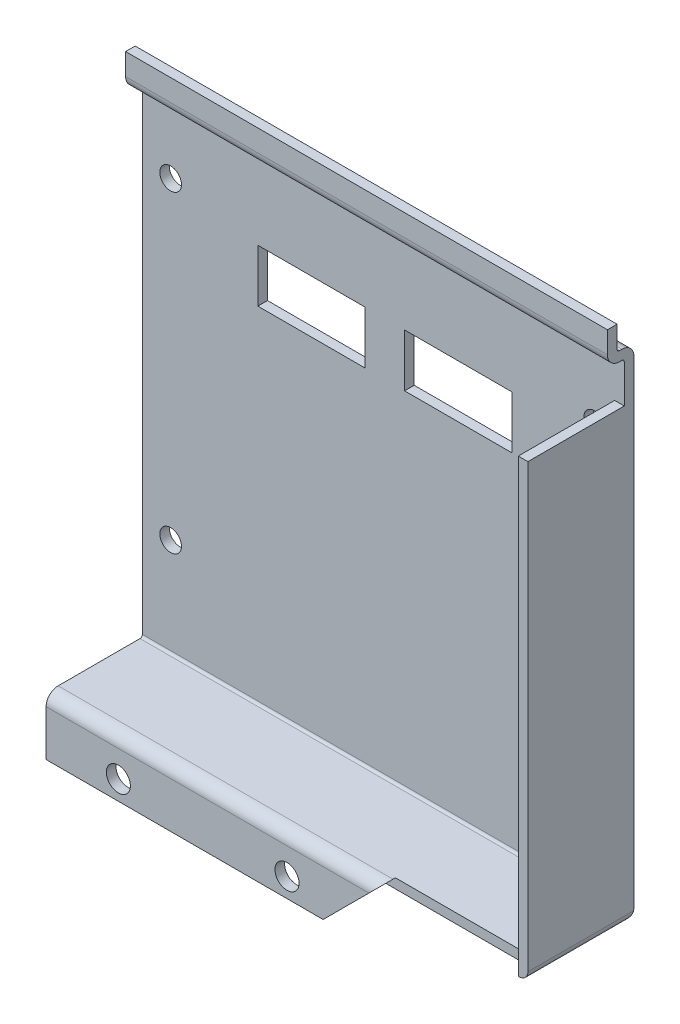
from build123d import *

# Parameters (mm, degrees)
BOSS_EXTRUDE1_DEPTH = 100
SKETCH2_W           = 2.5
SKETCH2_H           = 12.5
CUT_EXTRUDE1_DEPTH  = 21
SKETCH3_W           = 2
SKETCH3_H           = 93.5
BOSS_EXTRUDE2_DEPTH = 20
SKETCH4_R           = 2.5
CUT_EXTRUDE3_DEPTH  = 3
SKETCH5_R           = 2.25
SKETCH5_W           = 22.25
SKETCH5_H           = 10.95
CUT_EXTRUDE4_DEPTH  = 5
FILLET1_R           = 1.8


with BuildPart() as part:
    # Sketch1 → Boss-Extrude1 (new body)
    with BuildSketch(Plane(origin=(0, 0, 0), x_dir=(0, 0, -1), z_dir=(1, 0, 0))):
        with BuildLine():
            Line((0, -2.5), (0, -12))
            Line((0, -12), (2, -12))
            Line((2, -12), (2, -2.5))
            ThreePointArc((2, -2.5), (2.146446609, -2.146446609), (2.5, -2))
            Line((2.5, -2), (19.5, -2))
            ThreePointArc((19.5, -2), (21.267766953, -1.267766953), (22, 0.5))
            Line((22, 0.5), (22, 99.5))
            ThreePointArc((22, 99.5), (21.267766953, 101.267766953), (19.5, 102))
            Line((19.5, 102), (19, 102))
            ThreePointArc((19, 102), (18.646446609, 102.146446609), (18.5, 102.5))
            Line((18.5, 102.5), (18.5, 107))
            Line((18.5, 107), (16.5, 107))
            Line((16.5, 107), (16.5, 102.5))
            ThreePointArc((16.5, 102.5), (17.232233047, 100.732233047), (19, 100))
            Line((19, 100), (19.5, 100))
            ThreePointArc((19.5, 100), (19.853553391, 99.853553391), (20, 99.5))
            Line((20, 99.5), (20, 0.5))
            ThreePointArc((20, 0.5), (19.853553391, 0.146446609), (19.5, 0))
            Line((19.5, 0), (2.5, 0))
            ThreePointArc((2.5, 0), (0.732233047, -0.732233047), (0, -2.5))
        make_face()
    extrude(amount=BOSS_EXTRUDE1_DEPTH)

    # Sketch2 → Cut-Extrude1 (cut, through all)
    with BuildSketch(Plane.XY.offset(-20)):
        with Locations((98.75, -5.75)):
            Rectangle(SKETCH2_W, SKETCH2_H)
    extrude(amount=CUT_EXTRUDE1_DEPTH, mode=Mode.SUBTRACT)

    # Sketch3 → Boss-Extrude2 (add)
    with BuildSketch(Plane.XY.offset(-20)):
        with Locations((99, 44.800510257)):
            Rectangle(SKETCH3_W, SKETCH3_H)
    extrude(amount=BOSS_EXTRUDE2_DEPTH)

    # Sketch4 → Cut-Extrude3 (cut)
    with BuildSketch(Plane.XY):
        with Locations((15, -8)):
            Circle(SKETCH4_R)
        with Locations((50, -8)):
            Circle(SKETCH4_R)
        Polygon((97.5, 0), (69.5, 0), (57.5, -12), (97.5, -12), align=None)
    extrude(amount=-CUT_EXTRUDE3_DEPTH, mode=Mode.SUBTRACT)

    # Sketch5 → Cut-Extrude4 (cut)
    with BuildSketch(Plane.XY.offset(-20)):
        with Locations((5.85, 85.37)):
            Circle(SKETCH5_R)
        with Locations((5.85, 20.37)):
            Circle(SKETCH5_R)
        with Locations((93.85, 20.37)):
            Circle(SKETCH5_R)
        with Locations((93.85, 85.37)):
            Circle(SKETCH5_R)
        with Locations((35.075, 76.945)):
            Rectangle(SKETCH5_W, SKETCH5_H)
        with Locations((65.525, 76.945)):
            Rectangle(SKETCH5_W, SKETCH5_H)
    extrude(amount=-CUT_EXTRUDE4_DEPTH, mode=Mode.SUBTRACT)

    # Fillet1
    fillet1_edges = [part.edges().sort_by_distance(p)[0] for p in [
        (100, -1.949489743, -10),
    ]]
    fillet(fillet1_edges, radius=FILLET1_R)


solid = part.part
